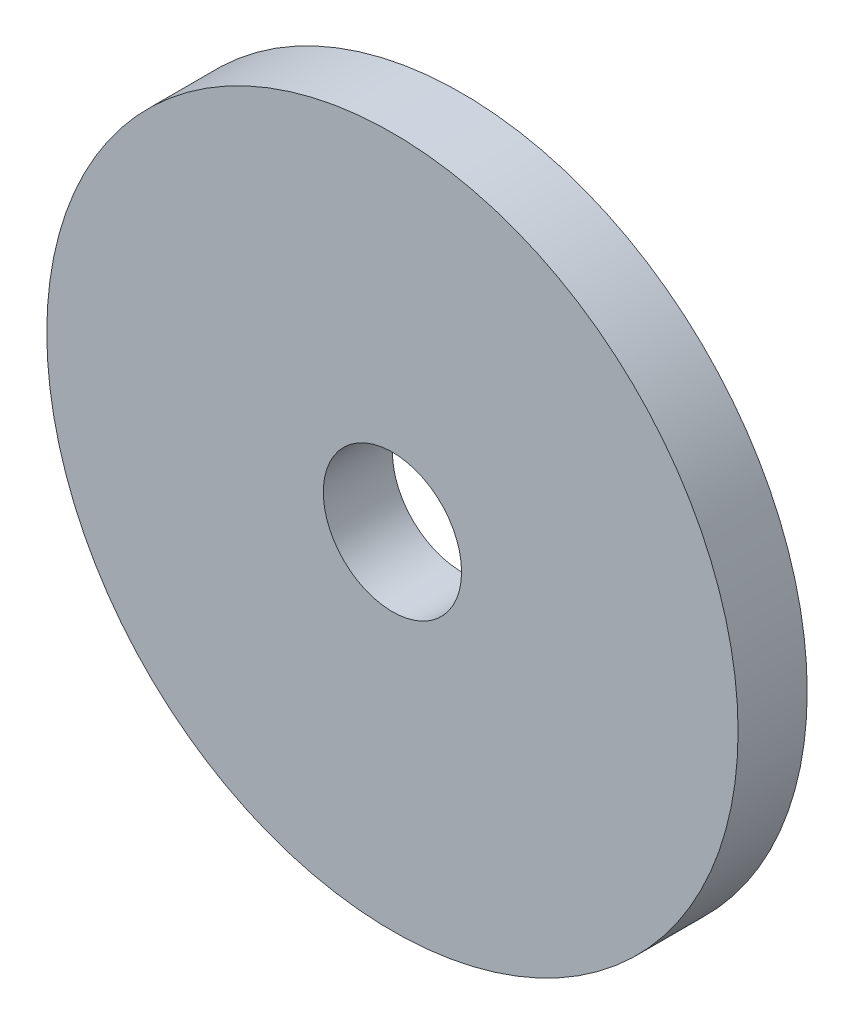
from build123d import *

# Parameters (mm, degrees)
SKETCH1_R           = 50
SKETCH1_R_2         = 10
BOSS_EXTRUDE1_DEPTH = 10


with BuildPart() as part:
    # Sketch1 → Boss-Extrude1 (new body)
    with BuildSketch(Plane.XY):
        Circle(SKETCH1_R)
        Circle(SKETCH1_R_2, mode=Mode.SUBTRACT)
    extrude(amount=BOSS_EXTRUDE1_DEPTH)


solid = part.part
